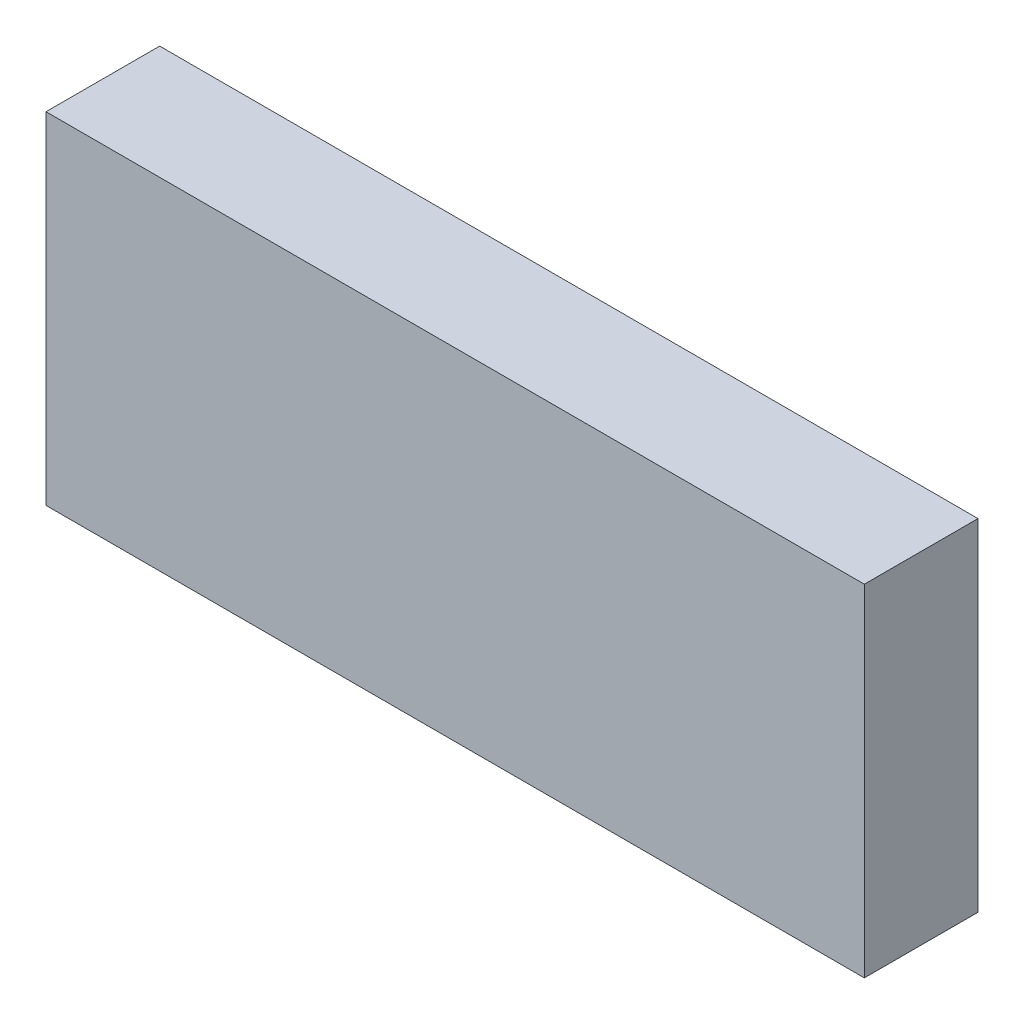
from build123d import *

# Parameters (mm, degrees)
SKETCH1_W           = 228.6
SKETCH1_H           = 95.25
BOSS_EXTRUDE1_DEPTH = 31.75


with BuildPart() as part:
    # Sketch1 → Boss-Extrude1 (new body)
    with BuildSketch(Plane.XY):
        with Locations((114.3, 47.625)):
            Rectangle(SKETCH1_W, SKETCH1_H)
    extrude(amount=BOSS_EXTRUDE1_DEPTH)


solid = part.part
